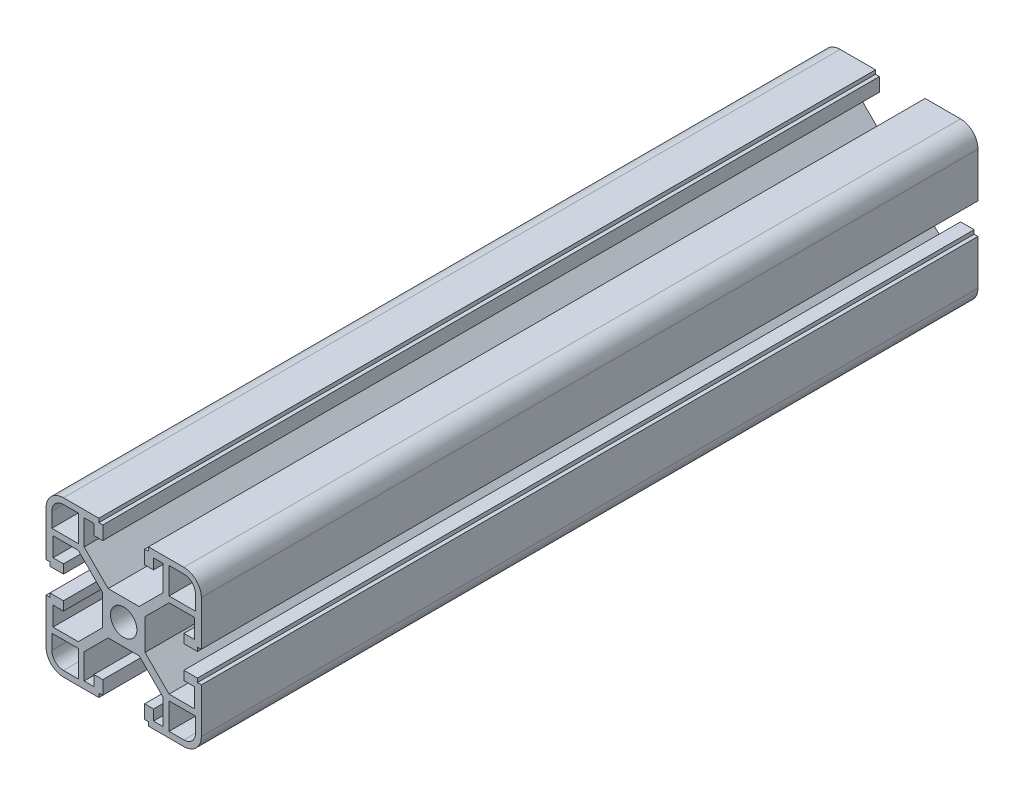
from build123d import *

# Parameters (mm, degrees)
BOSS_EXTRUDE1_DEPTH  = 200
MIRROR3_COPY_1_DEPTH = 200
MIRROR3_COPY_2_DEPTH = 200


with BuildPart() as part:
    # Sketch1 → Boss-Extrude1 (new body)
    with BuildSketch(Plane.XY):
        with BuildLine():
            Line((3.4, 0), (5.5, 0))
            Line((5.5, 0), (5.5, 4))
            Line((5.5, 4), (11.69, 10.19))
            Line((11.69, 10.19), (18.2, 10.19))
            Line((18.2, 10.19), (18.2, 5.265595036))
            Line((18.2, 5.265595036), (15.5, 5.265595036))
            Line((15.5, 5.265595036), (15.5, 2.965595036))
            Line((15.5, 2.965595036), (19, 2.965595036))
            Line((19, 2.965595036), (19, 3.965595036))
            Line((19, 3.965595036), (20, 3.965595036))
            Line((20, 3.965595036), (20, 15.5))
            ThreePointArc((20, 15.5), (18.681980515, 18.681980515), (15.5, 20))
            Line((15.5, 20), (6.385304712, 20))
            Line((6.385304712, 20), (6.385304712, 19))
            Line((6.385304712, 19), (5.385304712, 19))
            Line((5.385304712, 19), (5.385304712, 15.5))
            Line((5.385304712, 15.5), (7.685304712, 15.5))
            Line((7.685304712, 15.5), (7.685304712, 18.2))
            Line((7.685304712, 18.2), (10.19, 18.2))
            Line((10.19, 18.2), (10.19, 11.69))
            Line((10.19, 11.69), (4, 5.5))
            Line((4, 5.5), (0, 5.5))
            Line((0, 5.5), (0, 3.4))
            ThreePointArc((0, 3.4), (2.404163056, 2.404163056), (3.4, 0))
        make_face()
        with BuildLine():
            Line((18.5, 11.69), (18.5, 15.5))
            ThreePointArc((18.5, 15.5), (17.621320344, 17.621320344), (15.5, 18.5))
            Line((15.5, 18.5), (11.69, 18.5))
            Line((11.69, 18.5), (11.69, 11.69))
            Line((11.69, 11.69), (18.5, 11.69))
        make_face(mode=Mode.SUBTRACT)
    boss_extrude1 = extrude(amount=BOSS_EXTRUDE1_DEPTH)

    # Mirror1: Boss-Extrude1 across plane
    add(boss_extrude1.mirror(Plane.ZX))

    # Mirror2: Boss-Extrude1 across plane
    add(boss_extrude1.mirror(Plane(origin=(0, 0, 0), x_dir=(0, 0, 1), z_dir=(1, 0, 0))))

    # Mirror3 copy 1 sketch → Mirror3 copy 1 (add)
    with BuildSketch(Plane(origin=(0, 0, 0), x_dir=(-1, 0, 0), z_dir=(0, 0, 1))):
        with BuildLine():
            Line((3.4, 0), (5.5, 0))
            Line((5.5, 0), (5.5, 4))
            Line((5.5, 4), (11.69, 10.19))
            Line((11.69, 10.19), (18.2, 10.19))
            Line((18.2, 10.19), (18.2, 5.265595036))
            Line((18.2, 5.265595036), (15.5, 5.265595036))
            Line((15.5, 5.265595036), (15.5, 2.965595036))
            Line((15.5, 2.965595036), (19, 2.965595036))
            Line((19, 2.965595036), (19, 3.965595036))
            Line((19, 3.965595036), (20, 3.965595036))
            Line((20, 3.965595036), (20, 15.5))
            ThreePointArc((20, 15.5), (18.681980515, 18.681980515), (15.5, 20))
            Line((15.5, 20), (6.385304712, 20))
            Line((6.385304712, 20), (6.385304712, 19))
            Line((6.385304712, 19), (5.385304712, 19))
            Line((5.385304712, 19), (5.385304712, 15.5))
            Line((5.385304712, 15.5), (7.685304712, 15.5))
            Line((7.685304712, 15.5), (7.685304712, 18.2))
            Line((7.685304712, 18.2), (10.19, 18.2))
            Line((10.19, 18.2), (10.19, 11.69))
            Line((10.19, 11.69), (4, 5.5))
            Line((4, 5.5), (0, 5.5))
            Line((0, 5.5), (0, 3.4))
            ThreePointArc((0, 3.4), (2.404163056, 2.404163056), (3.4, 0))
        make_face()
        with BuildLine():
            Line((18.5, 11.69), (18.5, 15.5))
            ThreePointArc((18.5, 15.5), (17.621320344, 17.621320344), (15.5, 18.5))
            Line((15.5, 18.5), (11.69, 18.5))
            Line((11.69, 18.5), (11.69, 11.69))
            Line((11.69, 11.69), (18.5, 11.69))
        make_face(mode=Mode.SUBTRACT)
    extrude(amount=MIRROR3_COPY_1_DEPTH)

    # Mirror3 copy 2 sketch → Mirror3 copy 2 (add)
    with BuildSketch(Plane.XY):
        with BuildLine():
            Line((3.4, 0), (5.5, 0))
            Line((5.5, 0), (5.5, -4))
            Line((5.5, -4), (11.69, -10.19))
            Line((11.69, -10.19), (18.2, -10.19))
            Line((18.2, -10.19), (18.2, -5.265595036))
            Line((18.2, -5.265595036), (15.5, -5.265595036))
            Line((15.5, -5.265595036), (15.5, -2.965595036))
            Line((15.5, -2.965595036), (19, -2.965595036))
            Line((19, -2.965595036), (19, -3.965595036))
            Line((19, -3.965595036), (20, -3.965595036))
            Line((20, -3.965595036), (20, -15.5))
            ThreePointArc((20, -15.5), (18.681980515, -18.681980515), (15.5, -20))
            Line((15.5, -20), (6.385304712, -20))
            Line((6.385304712, -20), (6.385304712, -19))
            Line((6.385304712, -19), (5.385304712, -19))
            Line((5.385304712, -19), (5.385304712, -15.5))
            Line((5.385304712, -15.5), (7.685304712, -15.5))
            Line((7.685304712, -15.5), (7.685304712, -18.2))
            Line((7.685304712, -18.2), (10.19, -18.2))
            Line((10.19, -18.2), (10.19, -11.69))
            Line((10.19, -11.69), (4, -5.5))
            Line((4, -5.5), (0, -5.5))
            Line((0, -5.5), (0, -3.4))
            ThreePointArc((0, -3.4), (2.404163056, -2.404163056), (3.4, 0))
        make_face()
        with BuildLine():
            Line((18.5, -11.69), (18.5, -15.5))
            ThreePointArc((18.5, -15.5), (17.621320344, -17.621320344), (15.5, -18.5))
            Line((15.5, -18.5), (11.69, -18.5))
            Line((11.69, -18.5), (11.69, -11.69))
            Line((11.69, -11.69), (18.5, -11.69))
        make_face(mode=Mode.SUBTRACT)
    extrude(amount=MIRROR3_COPY_2_DEPTH)


solid = part.part
